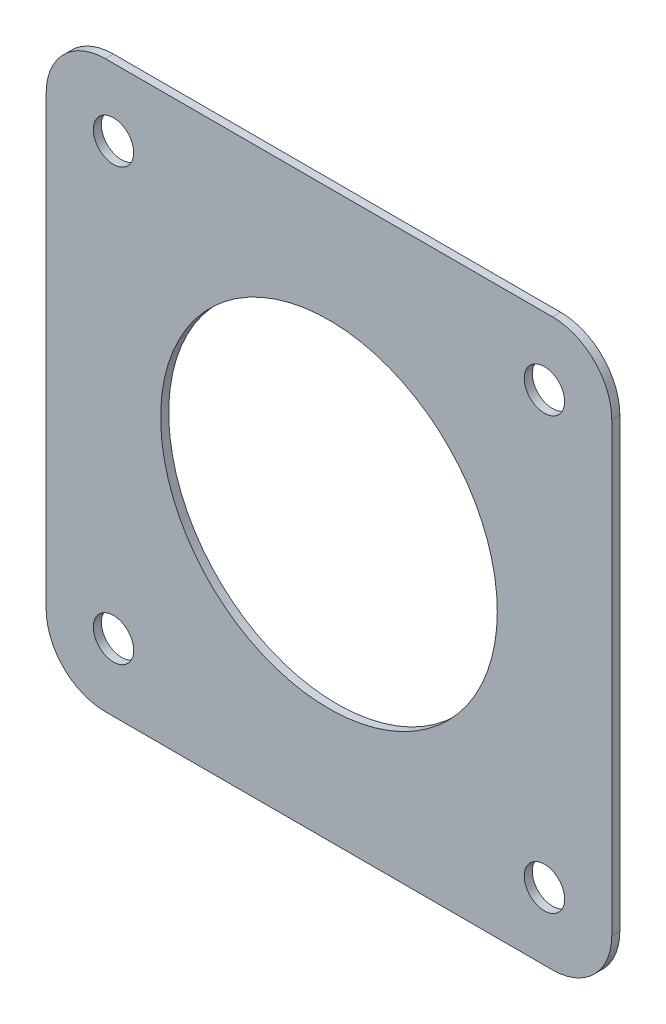
from build123d import *

# Parameters (mm, degrees)
SKETCH_1_R      = 7.5
SKETCH_1_R_2    = 62.5
EXTRUDE_1_DEPTH = 3


with BuildPart() as part:
    # Эскиз1 → Бобышка-Вытянуть1 (new body)
    with BuildSketch(Plane.XY):
        with BuildLine():
            Line((-83, -105), (83, -105))
            ThreePointArc((83, -105), (98.556349186, -98.556349186), (105, -83))
            Line((105, -83), (105, 83))
            ThreePointArc((105, 83), (98.556349186, 98.556349186), (83, 105))
            Line((83, 105), (-83, 105))
            ThreePointArc((-83, 105), (-98.556349186, 98.556349186), (-105, 83))
            Line((-105, 83), (-105, -83))
            ThreePointArc((-105, -83), (-98.556349186, -98.556349186), (-83, -105))
        make_face()
        with Locations((-80, 80)):
            Circle(SKETCH_1_R, mode=Mode.SUBTRACT)
        with Locations((80, 80)):
            Circle(SKETCH_1_R, mode=Mode.SUBTRACT)
        with Locations((80, -80)):
            Circle(SKETCH_1_R, mode=Mode.SUBTRACT)
        with Locations((-80, -80)):
            Circle(SKETCH_1_R, mode=Mode.SUBTRACT)
        Circle(SKETCH_1_R_2, mode=Mode.SUBTRACT)
    extrude(amount=EXTRUDE_1_DEPTH)


solid = part.part
